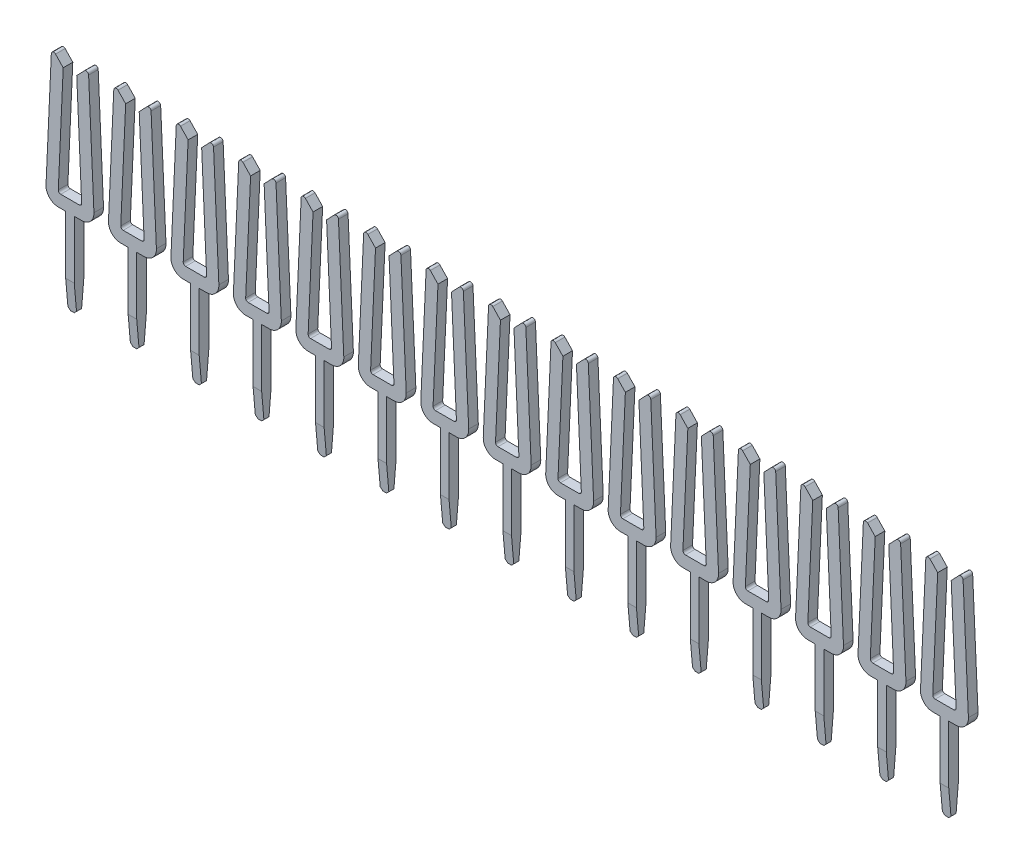
from build123d import *

# Parameters (mm, degrees)
EXTRUDE_684_DEPTH      = 0.195
CHAMFER_1_SIZE         = 0.1
CHAMFER_1_SIZE2        = 1.14300523
CHAMFER_2_SIZE         = 0.1
CHAMFER_2_SIZE2        = 1.14300523
PATTERN_LINEAR_1_COUNT = 15
PATTERN_LINEAR_1_PITCH = 2.54


with BuildPart() as part:
    # Sketch 211 → Extrude 684 (new, symmetric)
    with BuildSketch(Plane.XY):
        with BuildLine():
            Line((-0.275094226, 4.504536299), (-0.585991311, 4.829871514))
            ThreePointArc((-0.585991311, 4.829871514), (-0.693381247, 4.85442336), (-0.758184185, 4.765339295))
            Line((-0.758184185, 4.765339295), (-0.974480797, 0.022780107))
            ThreePointArc((-0.974480797, 0.022780107), (-0.836517671, -0.34540552), (-0.475, -0.5))
            Line((-0.475, -0.5), (-0.175, -0.5))
            Line((-0.175, -0.5), (-0.175, -3.9))
            Line((-0.175, -3.9), (-0.075, -4))
            Line((-0.075, -4), (0.075, -4))
            Line((0.075, -4), (0.175, -3.9))
            Line((0.175, -3.9), (0.175, -0.5))
            Line((0.175, -0.5), (0.475, -0.5))
            ThreePointArc((0.475, -0.5), (0.836517671, -0.34540552), (0.974480797, 0.022780107))
            Line((0.974480797, 0.022780107), (0.758184185, 4.765339295))
            ThreePointArc((0.758184185, 4.765339295), (0.693381247, 4.85442336), (0.585991311, 4.829871514))
            Line((0.585991311, 4.829871514), (0.275094226, 4.504536299))
            Line((0.275094226, 4.504536299), (0.474897057, 0.104536299))
            ThreePointArc((0.474897057, 0.104536299), (0.447296715, 0.030911759), (0.375, 0))
            Line((0.375, 0), (-0.375, 0))
            ThreePointArc((-0.375, 0), (-0.447296715, 0.030911759), (-0.474897057, 0.104536299))
            Line((-0.474897057, 0.104536299), (-0.275094226, 4.504536299))
        make_face()
    extrude(amount=EXTRUDE_684_DEPTH, both=True)

    # Фаска1
    chamfer_1_edges = [part.edges().sort_by_distance(p)[0] for p in [
        (0, -4, 0.195),
    ]]
    chamfer_1_side = [part.faces().sort_by_distance(p)[0] for p in [
        (0, -4, 0),
    ]]
    chamfer(chamfer_1_edges, length=CHAMFER_1_SIZE, length2=CHAMFER_1_SIZE2, reference=chamfer_1_side[0])

    # Фаска2
    chamfer_2_edges = [part.edges().sort_by_distance(p)[0] for p in [
        (0, -4, -0.195),
    ]]
    chamfer_2_side = [part.faces().sort_by_distance(p)[0] for p in [
        (0, -4, -0.05),
    ]]
    chamfer(chamfer_2_edges, length=CHAMFER_2_SIZE, length2=CHAMFER_2_SIZE2, reference=chamfer_2_side[0])


with BuildPart() as pattern_linear_1_1:
    # Линейный массив1: pattern copy
    add(part.part.moved(Location(Vector(-1, 0, 0) * (1 * PATTERN_LINEAR_1_PITCH))))


with BuildPart() as pattern_linear_1_2:
    # Линейный массив1: pattern copy
    add(part.part.moved(Location(Vector(-1, 0, 0) * (2 * PATTERN_LINEAR_1_PITCH))))


with BuildPart() as pattern_linear_1_3:
    # Линейный массив1: pattern copy
    add(part.part.moved(Location(Vector(-1, 0, 0) * (3 * PATTERN_LINEAR_1_PITCH))))


with BuildPart() as pattern_linear_1_4:
    # Линейный массив1: pattern copy
    add(part.part.moved(Location(Vector(-1, 0, 0) * (4 * PATTERN_LINEAR_1_PITCH))))


with BuildPart() as pattern_linear_1_5:
    # Линейный массив1: pattern copy
    add(part.part.moved(Location(Vector(-1, 0, 0) * (5 * PATTERN_LINEAR_1_PITCH))))


with BuildPart() as pattern_linear_1_6:
    # Линейный массив1: pattern copy
    add(part.part.moved(Location(Vector(-1, 0, 0) * (6 * PATTERN_LINEAR_1_PITCH))))


with BuildPart() as pattern_linear_1_7:
    # Линейный массив1: pattern copy
    add(part.part.moved(Location(Vector(-1, 0, 0) * (7 * PATTERN_LINEAR_1_PITCH))))


with BuildPart() as pattern_linear_1_8:
    # Линейный массив1: pattern copy
    add(part.part.moved(Location(Vector(-1, 0, 0) * (8 * PATTERN_LINEAR_1_PITCH))))


with BuildPart() as pattern_linear_1_9:
    # Линейный массив1: pattern copy
    add(part.part.moved(Location(Vector(-1, 0, 0) * (9 * PATTERN_LINEAR_1_PITCH))))


with BuildPart() as pattern_linear_1_10:
    # Линейный массив1: pattern copy
    add(part.part.moved(Location(Vector(-1, 0, 0) * (10 * PATTERN_LINEAR_1_PITCH))))


with BuildPart() as pattern_linear_1_11:
    # Линейный массив1: pattern copy
    add(part.part.moved(Location(Vector(-1, 0, 0) * (11 * PATTERN_LINEAR_1_PITCH))))


with BuildPart() as pattern_linear_1_12:
    # Линейный массив1: pattern copy
    add(part.part.moved(Location(Vector(-1, 0, 0) * (12 * PATTERN_LINEAR_1_PITCH))))


with BuildPart() as pattern_linear_1_13:
    # Линейный массив1: pattern copy
    add(part.part.moved(Location(Vector(-1, 0, 0) * (13 * PATTERN_LINEAR_1_PITCH))))


with BuildPart() as pattern_linear_1_14:
    # Линейный массив1: pattern copy
    add(part.part.moved(Location(Vector(-1, 0, 0) * (14 * PATTERN_LINEAR_1_PITCH))))


solid = Compound([part.part, pattern_linear_1_1.part, pattern_linear_1_2.part, pattern_linear_1_3.part, pattern_linear_1_4.part, pattern_linear_1_5.part, pattern_linear_1_6.part, pattern_linear_1_7.part, pattern_linear_1_8.part, pattern_linear_1_9.part, pattern_linear_1_10.part, pattern_linear_1_11.part, pattern_linear_1_12.part, pattern_linear_1_13.part, pattern_linear_1_14.part])
